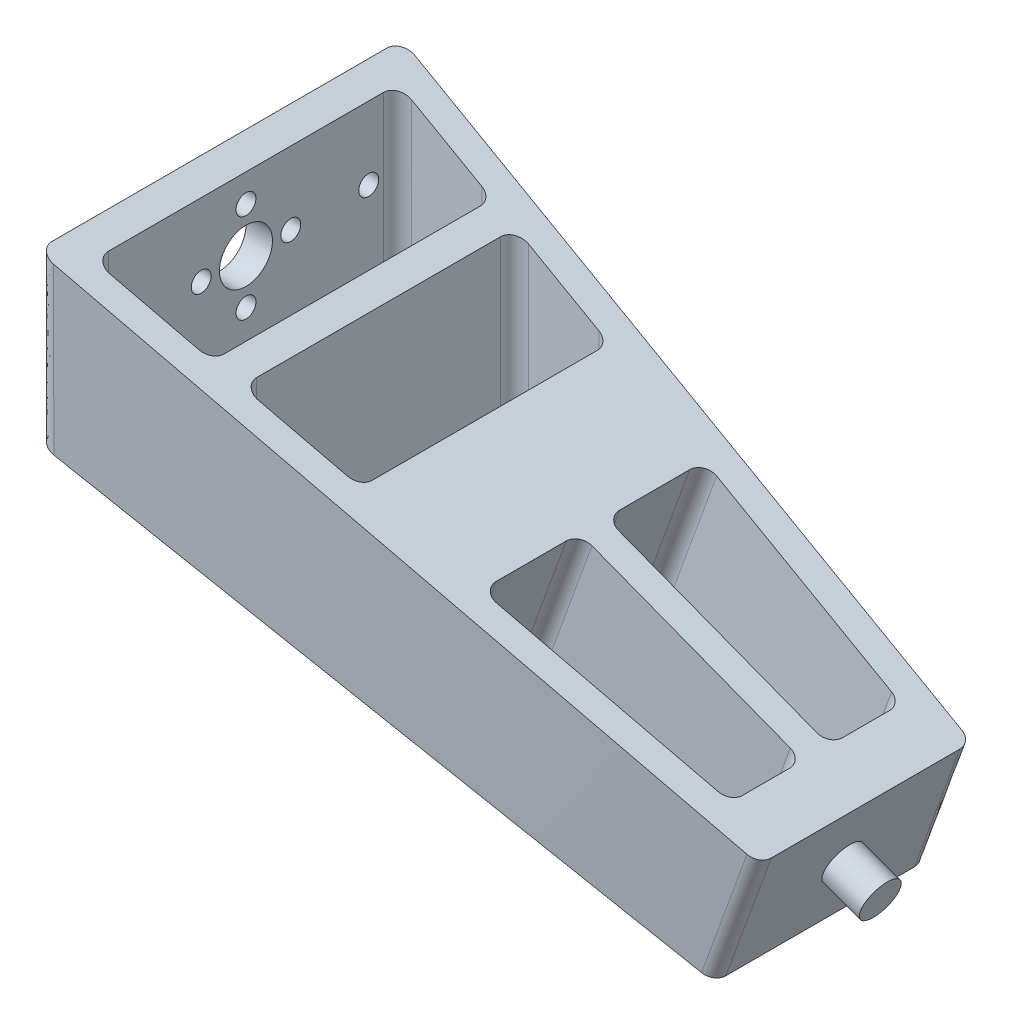
from build123d import *

# Parameters (mm, degrees)
SKETCH_3_W               = 32
SKETCH_3_H               = 20
SKETCH_2_W               = 55
SKETCH_2_H               = 25
SKETCH_4_R               = 3
EXTRUDE_1_DEPTH          = 6
FILLET_1_R               = 2
CUT_EXTRUDE_5_DEPTH      = 13.5000001
CUT_EXTRUDE_5_DEPTH_BACK = 44.59894064
CUT_EXTRUDE_4_DEPTH      = 47.164834503
CUT_EXTRUDE_4_DEPTH_BACK = 41.969602828
SKETCH_7_R               = 4
SKETCH_7_R_2             = 1.5
CUT_EXTRUDE_6_DEPTH      = 4


with BuildPart() as part:
    # Эскиз3 → По сечениям1 section 0
    with BuildSketch(Plane(origin=(93.969262079, -34.202014333, 0), x_dir=(0, 0, -1), z_dir=(0.939692621, -0.342020143, 0))):
        Rectangle(SKETCH_3_W, SKETCH_3_H)
    # Эскиз2 → По сечениям1 section 1
    with BuildSketch(Plane(origin=(0, 0, 0), x_dir=(0, 0, -1), z_dir=(1, 0, 0))):
        Rectangle(SKETCH_2_W, SKETCH_2_H)
    loft()

    # Эскиз4 → Бобышка-Вытянуть1 (add)
    with BuildSketch(Plane(origin=(93.969262079, -34.202014333, 0), x_dir=(0, 0, -1), z_dir=(0.939692621, -0.342020143, 0))):
        Circle(SKETCH_4_R)
    extrude(amount=EXTRUDE_1_DEPTH)

    # Скругление1
    fillet_1_edges = [part.edges().sort_by_distance(p)[0] for p in [
        (93.969262079, -34.202014333, 16),
        (93.969262079, -34.202014333, -16),
        (0, 0, -27.5),
        (0, 0, 27.5),
    ]]
    fillet(fillet_1_edges, radius=FILLET_1_R)

    # Эскиз5 → Вырез-Вытянуть5 (cut, two sides)
    with BuildSketch(Plane(origin=(0, 0, 0), x_dir=(1, 0, 0), z_dir=(0, 1, 0))) as cut_extrude_5_sk:
        with BuildLine():
            Line((18.234535714, 21.319028355), (6.234535714, 22.736019424))
            ThreePointArc((6.234535714, 22.736019424), (4.67129225, 22.24465513), (4, 20.74981878))
            Line((4, 20.74981878), (4, -20.74981878))
            ThreePointArc((4, -20.74981878), (4.67129225, -22.24465513), (6.234535714, -22.736019424))
            Line((6.234535714, -22.736019424), (18.234535714, -21.319028355))
            ThreePointArc((18.234535714, -21.319028355), (19.49483635, -20.661535461), (20, -19.332827711))
            Line((20, -19.332827711), (20, 19.332827711))
            ThreePointArc((20, 19.332827711), (19.49483635, 20.661535461), (18.234535714, 21.319028355))
        make_face()
        with BuildLine():
            Line((24, 18.388166999), (24, -18.388166999))
            ThreePointArc((24, -18.388166999), (24.67129225, -19.883003349), (26.234535714, -20.374367643))
            Line((26.234535714, -20.374367643), (38.234535714, -18.957376574))
            ThreePointArc((38.234535714, -18.957376574), (39.49483635, -18.29988368), (40, -16.97117593))
            Line((40, -16.97117593), (40, 16.97117593))
            ThreePointArc((40, 16.97117593), (39.49483635, 18.29988368), (38.234535714, 18.957376574))
            Line((38.234535714, 18.957376574), (26.234535714, 20.374367643))
            ThreePointArc((26.234535714, 20.374367643), (24.67129225, 19.883003349), (24, 18.388166999))
        make_face()
    extrude(amount=CUT_EXTRUDE_5_DEPTH, mode=Mode.SUBTRACT)
    extrude(cut_extrude_5_sk.sketch, amount=-CUT_EXTRUDE_5_DEPTH_BACK, mode=Mode.SUBTRACT)

    # Эскиз6 → Вырез-Вытянуть4 (cut, two sides)
    with BuildSketch(Plane(origin=(0, 0, 0), x_dir=(0.939692621, -0.342020143, 0), z_dir=(0.342020143, 0.939692621, 0))) as cut_extrude_4_sk:
        with BuildLine():
            Line((56, 14.595593465), (56, 4))
            ThreePointArc((56, 4), (56.585786438, 2.585786438), (58, 2))
            Line((58, 2), (90, 2))
            ThreePointArc((90, 2), (91.414213562, 2.585786438), (92, 4))
            Line((92, 4), (92, 11.066472282))
            ThreePointArc((92, 11.066472282), (91.489711655, 12.400923175), (90.219240814, 13.05441933))
            Line((90.219240814, 13.05441933), (58.219240814, 16.583540513))
            ThreePointArc((58.219240814, 16.583540513), (56.665549107, 16.08530512), (56, 14.595593465))
        make_face()
        with BuildLine():
            Line((92, -11.066472282), (92, -4))
            ThreePointArc((92, -4), (91.414213562, -2.585786438), (90, -2))
            Line((90, -2), (58, -2))
            ThreePointArc((58, -2), (56.585786438, -2.585786438), (56, -4))
            Line((56, -4), (56, -14.595593465))
            ThreePointArc((56, -14.595593465), (56.665549107, -16.08530512), (58.219240814, -16.583540513))
            Line((58.219240814, -16.583540513), (90.219240814, -13.05441933))
            ThreePointArc((90.219240814, -13.05441933), (91.489711655, -12.400923175), (92, -11.066472282))
        make_face()
    extrude(amount=CUT_EXTRUDE_4_DEPTH, mode=Mode.SUBTRACT)
    extrude(cut_extrude_4_sk.sketch, amount=-CUT_EXTRUDE_4_DEPTH_BACK, mode=Mode.SUBTRACT)

    # Эскиз7 → Вырез-Вытянуть6 (cut)
    with BuildSketch(Plane.ZY):
        Circle(SKETCH_7_R)
        with Locations((18.5, 0)):
            Circle(SKETCH_7_R_2)
        with Locations((-18.5, 0)):
            Circle(SKETCH_7_R_2)
        with Locations((0, 6.75)):
            Circle(SKETCH_7_R_2)
        with Locations((6.75, 0)):
            Circle(SKETCH_7_R_2)
        with Locations((0, -6.75)):
            Circle(SKETCH_7_R_2)
        with Locations((-6.75, 0)):
            Circle(SKETCH_7_R_2)
    extrude(amount=-CUT_EXTRUDE_6_DEPTH, mode=Mode.SUBTRACT)


solid = part.part
